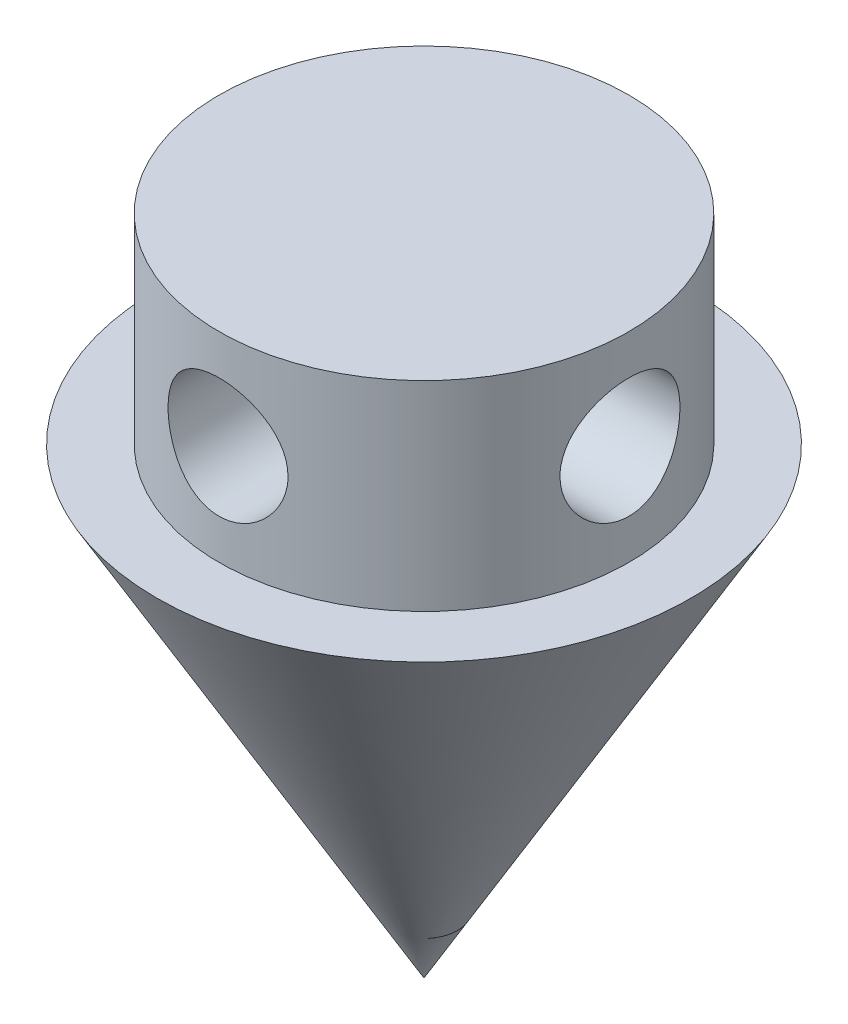
from build123d import *

# Parameters (mm, degrees)
SKETCH2_R          = 3
CUT_EXTRUDE1_DEPTH = 14.35
CIRPATTERN1_COUNT  = 2
CIRPATTERN1_ANGLE  = 90


with BuildPart() as part:
    # Sketch1 → Revolve1 (revolve)
    with BuildSketch(Plane.XY):
        Polygon((0, -16.561439141), (0, 16.561439141), (10.25, 16.561439141), (10.25, 6.561439141), (13.35, 6.561439141), align=None)
    revolve(axis=Axis((0, -24.573828125, 0), (0, 1, 0)))

    # Sketch2 → Cut-Extrude1 (cut, symmetric)
    with BuildSketch(Plane.XY):
        with Locations((0, 11.561439141)):
            Circle(SKETCH2_R)
    cut_extrude1 = extrude(amount=CUT_EXTRUDE1_DEPTH, both=True, mode=Mode.SUBTRACT)

    # CirPattern1: Cut-Extrude1 ×2 about axis
    cirpattern1_axis = Axis((0, -24.573828125, 0), (0, -1, 0))
    for i in range(1, CIRPATTERN1_COUNT):
        add(cut_extrude1.rotate(cirpattern1_axis, i * CIRPATTERN1_ANGLE / (CIRPATTERN1_COUNT - 1)), mode=Mode.SUBTRACT)


solid = part.part
